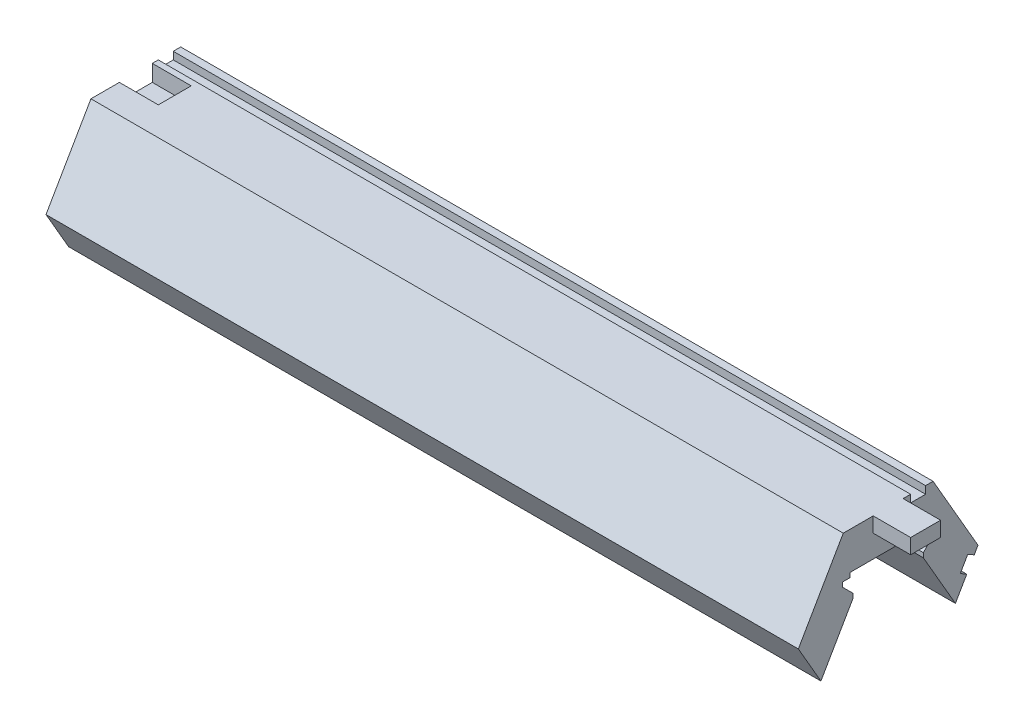
from build123d import *

# Parameters (mm, degrees)
BOSS_EXTRUDE2_DEPTH = 50.25
SKETCH3_W           = 2
SKETCH3_H           = 1
CUT_EXTRUDE2_DEPTH  = 101.5
SKETCH4_W           = 4
SKETCH4_H           = 2
BOSS_EXTRUDE3_DEPTH = 5
CUT_EXTRUDE3_DEPTH  = 5.2


with BuildPart() as part:
    # LED Segment → Boss-Extrude2 (new body, symmetric)
    with BuildSketch(Plane(origin=(0, 0, 0), x_dir=(0, 0, -1), z_dir=(1, 0, 0))):
        Polygon((8.982863896, -5.225833025), (12, 0), (6, 10.392304845), (-6, 10.392304845), (-12, 0), (-8.982863896, -5.225833025), (-4.7, 2.192304845), (-4.7, 2.792304845), (-6.1, 4.192304845), (-6.1, 4.792304845), (-5.1, 4.792304845), (-5.1, 5.392304845), (5.1, 5.392304845), (5.1, 4.792304845), (6.1, 4.792304845), (6.1, 4.192304845), (4.7, 2.792304845), (4.7, 2.192304845), align=None)
    extrude(amount=BOSS_EXTRUDE2_DEPTH, both=True)

    # Sketch3 → Cut-Extrude2 (cut, through all)
    with BuildSketch(Plane(origin=(50.25, 0, 0), x_dir=(0, 0, -1), z_dir=(1, 0, 0))):
        with Locations((4, 9.892304845)):
            Rectangle(SKETCH3_W, SKETCH3_H)
        Polygon((10.5, -2.598076211), (11.5, -0.866025404), (10.633974596, -0.366025404), (9.633974596, -2.098076211), align=None)
    extrude(amount=-CUT_EXTRUDE2_DEPTH, mode=Mode.SUBTRACT)

    # Sketch4 → Boss-Extrude3 (add)
    with BuildSketch(Plane(origin=(50.25, 0, 0), x_dir=(0, 0, -1), z_dir=(1, 0, 0))):
        with Locations((0, 9.392304845)):
            Rectangle(SKETCH4_W, SKETCH4_H)
    extrude(amount=BOSS_EXTRUDE3_DEPTH)

    # Sketch5 → Cut-Extrude3 (cut)
    with BuildSketch(Plane.ZY.offset(50.25)):
        Polygon((-2.2, 10.392304845), (-2.2, 8.192304845), (2.2, 8.192304845), (2.2, 10.392304845), (2, 10.392304845), (-2, 10.392304845), align=None)
    extrude(amount=-CUT_EXTRUDE3_DEPTH, mode=Mode.SUBTRACT)


solid = part.part
